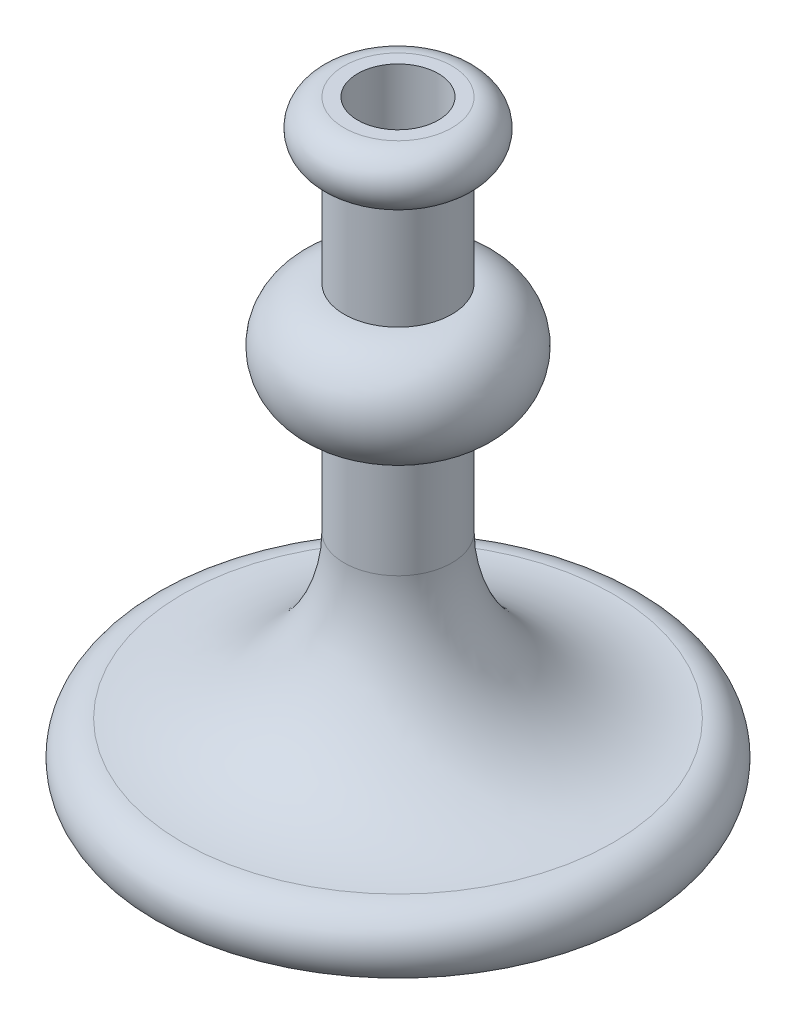
from build123d import *

# Parameters (mm, degrees)
SKETCH2_R          = 381
CUT_EXTRUDE1_DEPTH = 5589.000000354


with BuildPart() as part:
    # Sketch1 → Revolve1 (revolve)
    with BuildSketch(Plane.XY):
        with BuildLine():
            Line((0, 0), (2286, 0))
            ThreePointArc((2286, 0), (2315.980633142, 332.490316571), (2032, 508))
            ThreePointArc((2032, 508), (954.369265472, 954.369265472), (508, 2032))
            Line((508, 2032), (508, 3048))
            ThreePointArc((508, 3048), (1016, 3556), (508, 4064))
            Line((508, 4064), (508, 5080))
            ThreePointArc((508, 5080), (762, 5334), (508, 5588))
            Line((508, 5588), (0, 5588))
            Line((0, 5588), (0, 0))
        make_face()
    revolve(axis=Axis((0, 0, 0), (0, 1, 0)))

    # Sketch2 → Cut-Extrude1 (cut, through all)
    with BuildSketch(Plane(origin=(0, 5588, 0), x_dir=(1, 0, 0), z_dir=(0, 1, 0))):
        Circle(SKETCH2_R)
    extrude(amount=-CUT_EXTRUDE1_DEPTH, mode=Mode.SUBTRACT)


solid = part.part
